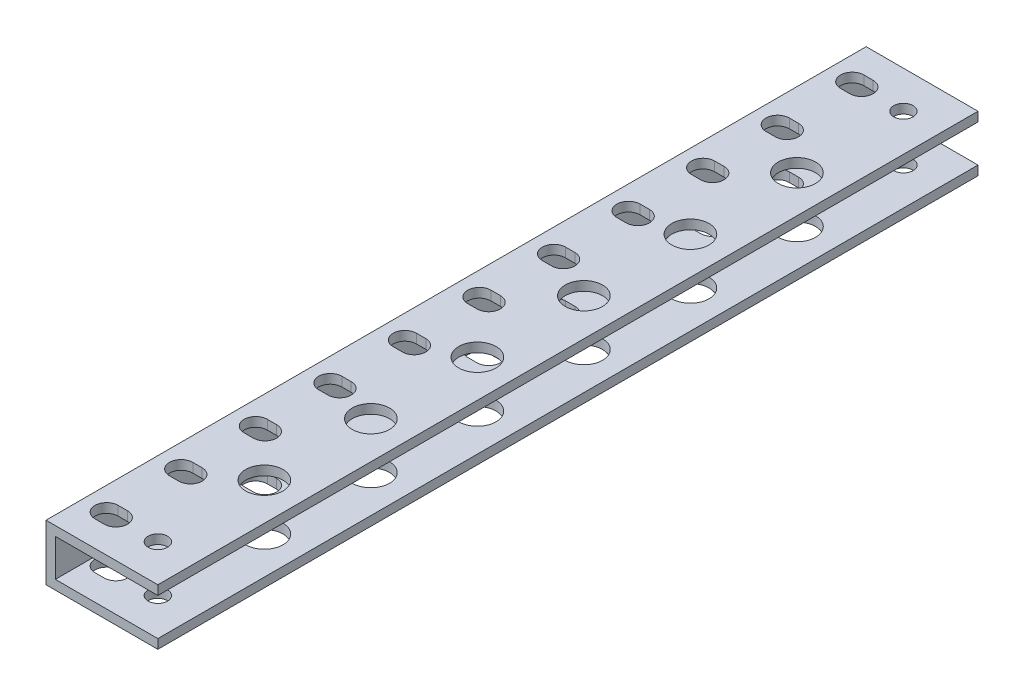
from build123d import *

# Parameters (mm, degrees)
SKETCH1_W           = 38.1
SKETCH1_H           = 279.4
BOSS_EXTRUDE1_DEPTH = 19.05
SKETCH2_R           = 6.35
SKETCH2_R_2         = 3.302
CUT_EXTRUDE1_DEPTH  = 20.05
SKETCH3_W           = 34.925
SKETCH3_H           = 12.7
CUT_EXTRUDE2_DEPTH  = 330.2


with BuildPart() as part:
    # Sketch1 → Boss-Extrude1 (new body)
    with BuildSketch(Plane(origin=(0, 0, 0), x_dir=(1, 0, 0), z_dir=(0, 1, 0))):
        with Locations((19.05, 139.7)):
            Rectangle(SKETCH1_W, SKETCH1_H)
        with BuildLine():
            Line((7.9375, 270.66875), (11.1125, 270.66875))
            ThreePointArc((11.1125, 270.66875), (15.08125, 266.7), (11.1125, 262.73125))
            Line((11.1125, 262.73125), (7.9375, 262.73125))
            ThreePointArc((7.9375, 262.73125), (3.96875, 266.7), (7.9375, 270.66875))
        make_face(mode=Mode.SUBTRACT)
        with BuildLine():
            Line((7.9375, 237.33125), (11.1125, 237.33125))
            ThreePointArc((11.1125, 237.33125), (15.08125, 241.3), (11.1125, 245.26875))
            Line((11.1125, 245.26875), (7.9375, 245.26875))
            ThreePointArc((7.9375, 245.26875), (3.96875, 241.3), (7.9375, 237.33125))
        make_face(mode=Mode.SUBTRACT)
        with BuildLine():
            Line((7.9375, 211.93125), (11.1125, 211.93125))
            ThreePointArc((11.1125, 211.93125), (15.08125, 215.9), (11.1125, 219.86875))
            Line((11.1125, 219.86875), (7.9375, 219.86875))
            ThreePointArc((7.9375, 219.86875), (3.96875, 215.9), (7.9375, 211.93125))
        make_face(mode=Mode.SUBTRACT)
        with BuildLine():
            Line((7.9375, 186.53125), (11.1125, 186.53125))
            ThreePointArc((11.1125, 186.53125), (15.08125, 190.5), (11.1125, 194.46875))
            Line((11.1125, 194.46875), (7.9375, 194.46875))
            ThreePointArc((7.9375, 194.46875), (3.96875, 190.5), (7.9375, 186.53125))
        make_face(mode=Mode.SUBTRACT)
        with BuildLine():
            Line((7.9375, 161.13125), (11.1125, 161.13125))
            ThreePointArc((11.1125, 161.13125), (15.08125, 165.1), (11.1125, 169.06875))
            Line((11.1125, 169.06875), (7.9375, 169.06875))
            ThreePointArc((7.9375, 169.06875), (3.96875, 165.1), (7.9375, 161.13125))
        make_face(mode=Mode.SUBTRACT)
        with BuildLine():
            Line((7.9375, 135.73125), (11.1125, 135.73125))
            ThreePointArc((11.1125, 135.73125), (15.08125, 139.7), (11.1125, 143.66875))
            Line((11.1125, 143.66875), (7.9375, 143.66875))
            ThreePointArc((7.9375, 143.66875), (3.96875, 139.7), (7.9375, 135.73125))
        make_face(mode=Mode.SUBTRACT)
        with BuildLine():
            Line((7.9375, 110.33125), (11.1125, 110.33125))
            ThreePointArc((11.1125, 110.33125), (15.08125, 114.3), (11.1125, 118.26875))
            Line((11.1125, 118.26875), (7.9375, 118.26875))
            ThreePointArc((7.9375, 118.26875), (3.96875, 114.3), (7.9375, 110.33125))
        make_face(mode=Mode.SUBTRACT)
        with BuildLine():
            Line((7.9375, 84.93125), (11.1125, 84.93125))
            ThreePointArc((11.1125, 84.93125), (15.08125, 88.9), (11.1125, 92.86875))
            Line((11.1125, 92.86875), (7.9375, 92.86875))
            ThreePointArc((7.9375, 92.86875), (3.96875, 88.9), (7.9375, 84.93125))
        make_face(mode=Mode.SUBTRACT)
        with BuildLine():
            Line((7.9375, 59.53125), (11.1125, 59.53125))
            ThreePointArc((11.1125, 59.53125), (15.08125, 63.5), (11.1125, 67.46875))
            Line((11.1125, 67.46875), (7.9375, 67.46875))
            ThreePointArc((7.9375, 67.46875), (3.96875, 63.5), (7.9375, 59.53125))
        make_face(mode=Mode.SUBTRACT)
        with BuildLine():
            Line((7.9375, 34.13125), (11.1125, 34.13125))
            ThreePointArc((11.1125, 34.13125), (15.08125, 38.1), (11.1125, 42.06875))
            Line((11.1125, 42.06875), (7.9375, 42.06875))
            ThreePointArc((7.9375, 42.06875), (3.96875, 38.1), (7.9375, 34.13125))
        make_face(mode=Mode.SUBTRACT)
        with BuildLine():
            Line((7.9375, 8.73125), (11.1125, 8.73125))
            ThreePointArc((11.1125, 8.73125), (15.08125, 12.7), (11.1125, 16.66875))
            Line((11.1125, 16.66875), (7.9375, 16.66875))
            ThreePointArc((7.9375, 16.66875), (3.96875, 12.7), (7.9375, 8.73125))
        make_face(mode=Mode.SUBTRACT)
    extrude(amount=BOSS_EXTRUDE1_DEPTH)

    # Sketch2 → Cut-Extrude1 (cut, through all)
    with BuildSketch(Plane(origin=(0, 19.05, 0), x_dir=(1, 0, 0), z_dir=(0, 1, 0))):
        with Locations((25.4, 230.414285714)):
            Circle(SKETCH2_R)
        with Locations((25.4, 194.128571429)):
            Circle(SKETCH2_R)
        with Locations((25.4, 157.842857143)):
            Circle(SKETCH2_R)
        with Locations((25.4, 121.557142857)):
            Circle(SKETCH2_R)
        with Locations((25.4, 85.271428571)):
            Circle(SKETCH2_R)
        with Locations((25.4, 48.985714286)):
            Circle(SKETCH2_R)
        with Locations((25.4, 266.7)):
            Circle(SKETCH2_R_2)
        with Locations((25.4, 12.7)):
            Circle(SKETCH2_R_2)
    extrude(amount=-CUT_EXTRUDE1_DEPTH, mode=Mode.SUBTRACT)

    # Sketch3 → Cut-Extrude2 (cut)
    with BuildSketch(Plane.XY):
        with Locations((20.6375, 9.525)):
            Rectangle(SKETCH3_W, SKETCH3_H)
    extrude(amount=-CUT_EXTRUDE2_DEPTH, mode=Mode.SUBTRACT)


solid = part.part
